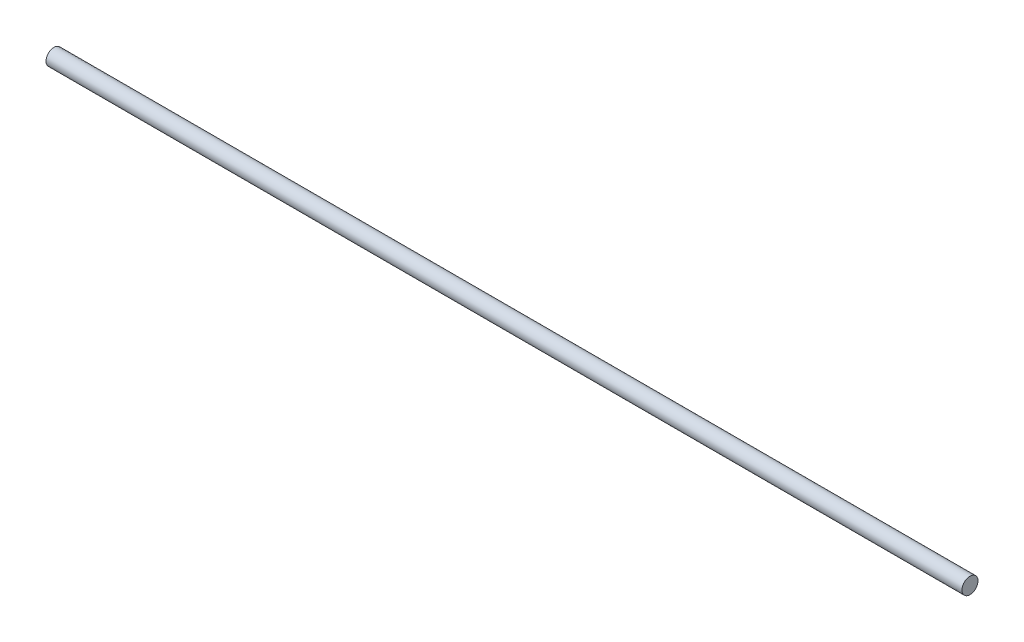
from build123d import *

# Parameters (mm, degrees)
SKETCH1_R           = 1.778
BOSS_EXTRUDE1_DEPTH = 101.6


with BuildPart() as part:
    # Sketch1 → Boss-Extrude1 (new body, symmetric)
    with BuildSketch(Plane(origin=(0, 0, 0), x_dir=(0, 0, -1), z_dir=(1, 0, 0))):
        Circle(SKETCH1_R)
    extrude(amount=BOSS_EXTRUDE1_DEPTH, both=True)


solid = part.part
